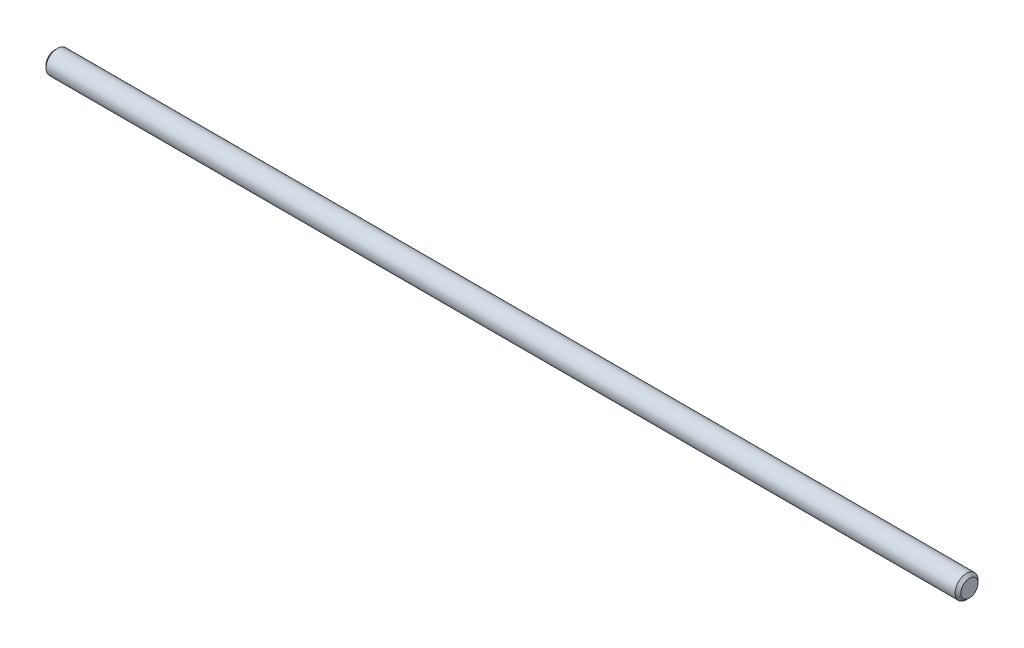
from build123d import *

# Parameters (mm, degrees)
SKETCH2_R           = 1.5
BOSS_EXTRUDE1_DEPTH = 60
CHAMFER1_SIZE       = 0.375


with BuildPart() as part:
    # Sketch2 → Boss-Extrude1 (new, symmetric)
    with BuildSketch(Plane(origin=(0, 0, 0), x_dir=(0, 0, -1), z_dir=(1, 0, 0))):
        Circle(SKETCH2_R)
    extrude(amount=BOSS_EXTRUDE1_DEPTH, both=True)

    # Chamfer1
    chamfer1_edges = [part.edges().sort_by_distance(p)[0] for p in [
        (-60, 0, 1.5),
        (60, 0, 1.5),
    ]]
    chamfer(chamfer1_edges, length=CHAMFER1_SIZE)


solid = part.part
